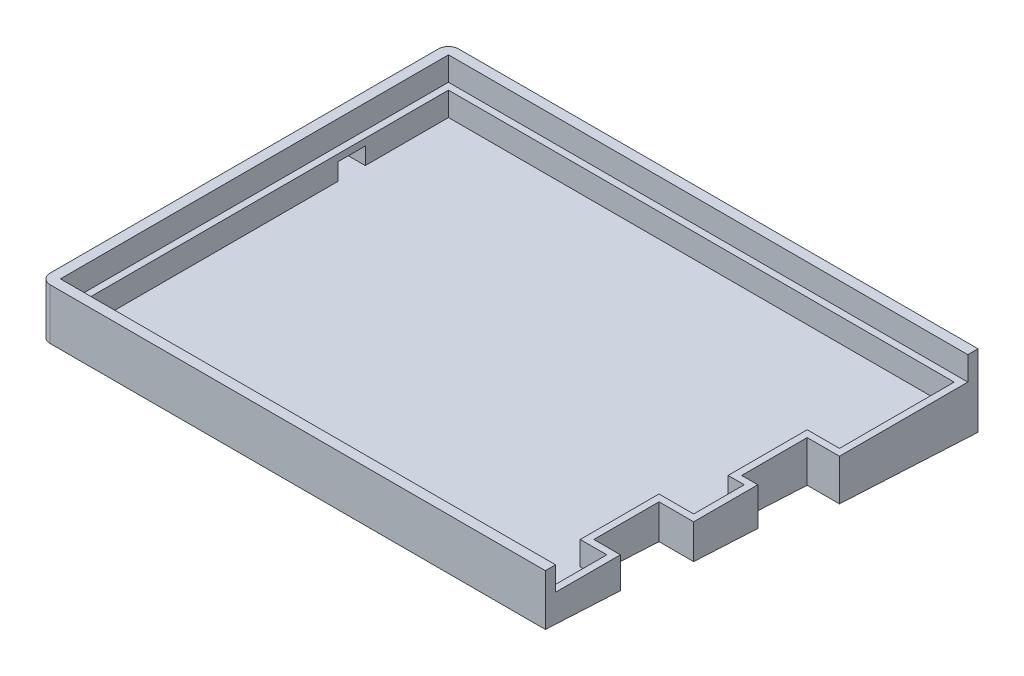
from build123d import *

# Parameters (mm, degrees)
BOSS_EXTRUDE1_DEPTH = 14
BOSS_EXTRUDE2_DEPTH = 1
BOSS_EXTRUDE3_DEPTH = 155.94
SKETCH1_5_W         = 14.94
SKETCH1_5_H         = 3
CUT_EXTRUDE1_DEPTH  = 10
BOSS_EXTRUDE4_DEPTH = 7.83
FILLET1_R           = 3
BOSS_EXTRUDE5_DEPTH = 7
SKETCH5_W           = 8.1
SKETCH5_H           = 5
CUT_EXTRUDE2_DEPTH  = 5


with BuildPart() as part:
    # Sketch1 → Boss-Extrude1 (new body)
    with BuildSketch(Plane(origin=(0, 0, 0), x_dir=(1, 0, 0), z_dir=(0, 1, 0))):
        Polygon((152.94, 117.29), (152.94, 114.29), (0, 114.29), (0, 0), (138, 0), (138, -3), (-3, -3), (-3, 117.29), align=None)
    extrude(amount=BOSS_EXTRUDE1_DEPTH)

    # Sketch1_3 → Boss-Extrude2 (add)
    with BuildSketch(Plane(origin=(0, 0, 0), x_dir=(1, 0, 0), z_dir=(0, 1, 0))):
        Polygon((138, 38.29), (138, 0), (0, 0), (0, 114.29), (152.94, 114.29), (152.94, 76.49), (143.44, 76.49), (143.44, 57.19), (148.2, 57.19), (148.2, 38.29), align=None)
        Polygon((152.94, 117.29), (152.94, 114.29), (0, 114.29), (0, 0), (138, 0), (138, -3), (-3, -3), (-3, 117.29), align=None)
    extrude(amount=-BOSS_EXTRUDE2_DEPTH)

    # Sketch2 → Boss-Extrude3 (add)
    with BuildSketch(Plane(origin=(152.94, 0, 0), x_dir=(0, 0, -1), z_dir=(1, 0, 0))):
        Polygon((117.29, 0), (117.29, -7.30413177), (-3, -1), (-3, 0), align=None)
    extrude(amount=-BOSS_EXTRUDE3_DEPTH)

    # Sketch1_5 → Cut-Extrude1 (cut)
    with BuildSketch(Plane(origin=(0, 0, 0), x_dir=(1, 0, 0), z_dir=(0, 1, 0))):
        with Locations((145.47, -1.5)):
            Rectangle(SKETCH1_5_W, SKETCH1_5_H)
        Polygon((138, 0), (152.94, 0), (152.94, 76.49), (143.44, 76.49), (143.44, 57.19), (148.2, 57.19), (148.2, 38.29), (138, 38.29), align=None)
    extrude(amount=-CUT_EXTRUDE1_DEPTH, mode=Mode.SUBTRACT)

    # Sketch3 → Boss-Extrude4 (add)
    with BuildSketch(Plane(origin=(138, 0, 0), x_dir=(0, 0, -1), z_dir=(1, 0, 0))):
        Polygon((19.09, -2.157687844), (19.09, 0), (0, 0), (0, 14), (-3, 14), (-3, -1), align=None)
    extrude(amount=BOSS_EXTRUDE4_DEPTH)

    # Fillet1
    fillet1_edges = [part.edges().sort_by_distance(p)[0] for p in [
        (-3, 6.5, 3),
        (-3, 3.347934115, -117.29),
    ]]
    fillet(fillet1_edges, radius=FILLET1_R)

    # Sketch4 → Boss-Extrude5 (add)
    with BuildSketch(Plane(origin=(0, 0, 0), x_dir=(1, 0, 0), z_dir=(0, 1, 0))):
        Polygon((0, 0), (145.83, 0), (145.83, 19.09), (138, 19.09), (138, 38.29), (148.2, 38.29), (148.2, 57.19), (143.44, 57.19), (143.44, 76.49), (152.94, 76.49), (152.94, 114.29), (0, 114.29), align=None)
        Polygon((150.94, 112.29), (2, 112.29), (2, 2), (143.83, 2), (143.83, 17.09), (136, 17.09), (136, 40.29), (146.2, 40.29), (146.2, 55.19), (141.44, 55.19), (141.44, 78.49), (150.94, 78.49), align=None, mode=Mode.SUBTRACT)
    extrude(amount=BOSS_EXTRUDE5_DEPTH)

    # Sketch5 → Cut-Extrude2 (cut)
    with BuildSketch(Plane(origin=(2, 0, 0), x_dir=(0, 0, -1), z_dir=(1, 0, 0))):
        with Locations((83.74, 2.5)):
            Rectangle(SKETCH5_W, SKETCH5_H)
    extrude(amount=-CUT_EXTRUDE2_DEPTH, mode=Mode.SUBTRACT)


solid = part.part
